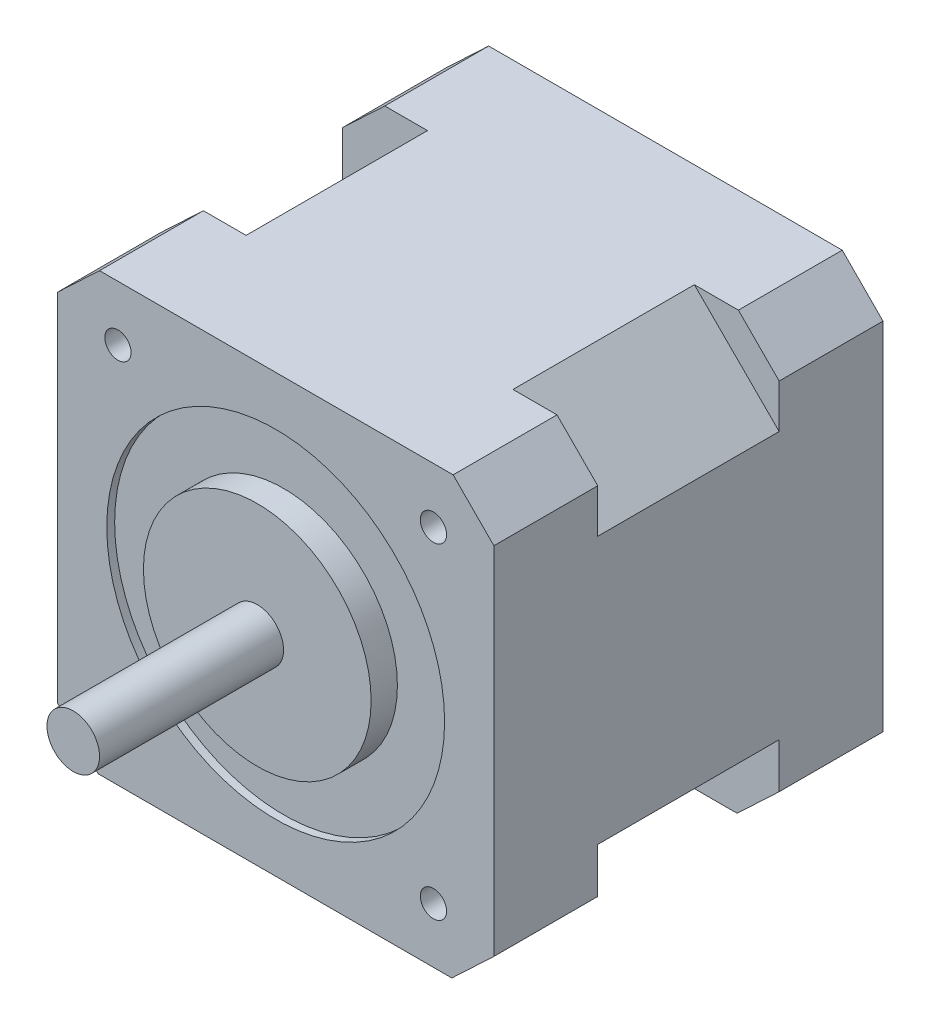
from build123d import *

# Parameters (mm, degrees)
BOSS_EXTRUDE1_DEPTH = 10.033
BOSS_EXTRUDE2_DEPTH = 18.034
SKETCH3_R           = 16.3195
CUT_EXTRUDE1_DEPTH  = 0.762
SKETCH4_R           = 10.9982
BOSS_EXTRUDE3_DEPTH = 2.54
SKETCH5_R           = 2.54
BOSS_EXTRUDE4_DEPTH = 17.78
SKETCH6_R           = 1.27
CUT_EXTRUDE2_DEPTH  = 7.62


with BuildPart() as part:
    # Sketch1 → Boss-Extrude1 (new body)
    with BuildSketch(Plane.XY):
        Polygon((-21.082, 17.246684107), (-17.018, 21.082), (17.145, 21.082), (21.082, 17.116426271), (21.082, -17.246684107), (17.018, -21.082), (-17.145, -21.082), (-21.082, -17.116426271), align=None)
    boss_extrude1 = extrude(amount=-BOSS_EXTRUDE1_DEPTH)

    # Sketch2 → Boss-Extrude2 (add)
    with BuildSketch(Plane(origin=(0, 0, -10.033), x_dir=(-1, 0, 0), z_dir=(0, 0, -1))):
        Polygon((-21.082, 12.892006418), (-12.892006418, 21.082), (12.892006418, 21.082), (21.082, 12.892006418), (21.082, -12.892006418), (12.892006418, -21.082), (-12.892006418, -21.082), (-21.082, -12.892006418), align=None)
    extrude(amount=BOSS_EXTRUDE2_DEPTH)

    # Mirror2: Boss-Extrude1 across plane
    add(boss_extrude1.mirror(Plane.XY.offset(-18.796)))

    # Sketch3 → Cut-Extrude1 (cut)
    with BuildSketch(Plane.XY):
        Circle(SKETCH3_R)
    extrude(amount=-CUT_EXTRUDE1_DEPTH, mode=Mode.SUBTRACT)

    # Sketch4 → Boss-Extrude3 (add)
    with BuildSketch(Plane.XY.offset(-0.762)):
        Circle(SKETCH4_R)
    extrude(amount=BOSS_EXTRUDE3_DEPTH)

    # Sketch5 → Boss-Extrude4 (add)
    with BuildSketch(Plane.XY.offset(1.778)):
        Circle(SKETCH5_R)
    extrude(amount=BOSS_EXTRUDE4_DEPTH)

    # Sketch6 → Cut-Extrude2 (cut)
    with BuildSketch(Plane.XY):
        with Locations((-15.24, 15.748)):
            Circle(SKETCH6_R)
        with Locations((15.24, 15.748)):
            Circle(SKETCH6_R)
    cut_extrude2 = extrude(amount=-CUT_EXTRUDE2_DEPTH, mode=Mode.SUBTRACT)

    # Mirror3: Cut-Extrude2 across plane
    add(cut_extrude2.mirror(Plane.ZX), mode=Mode.SUBTRACT)


solid = part.part
